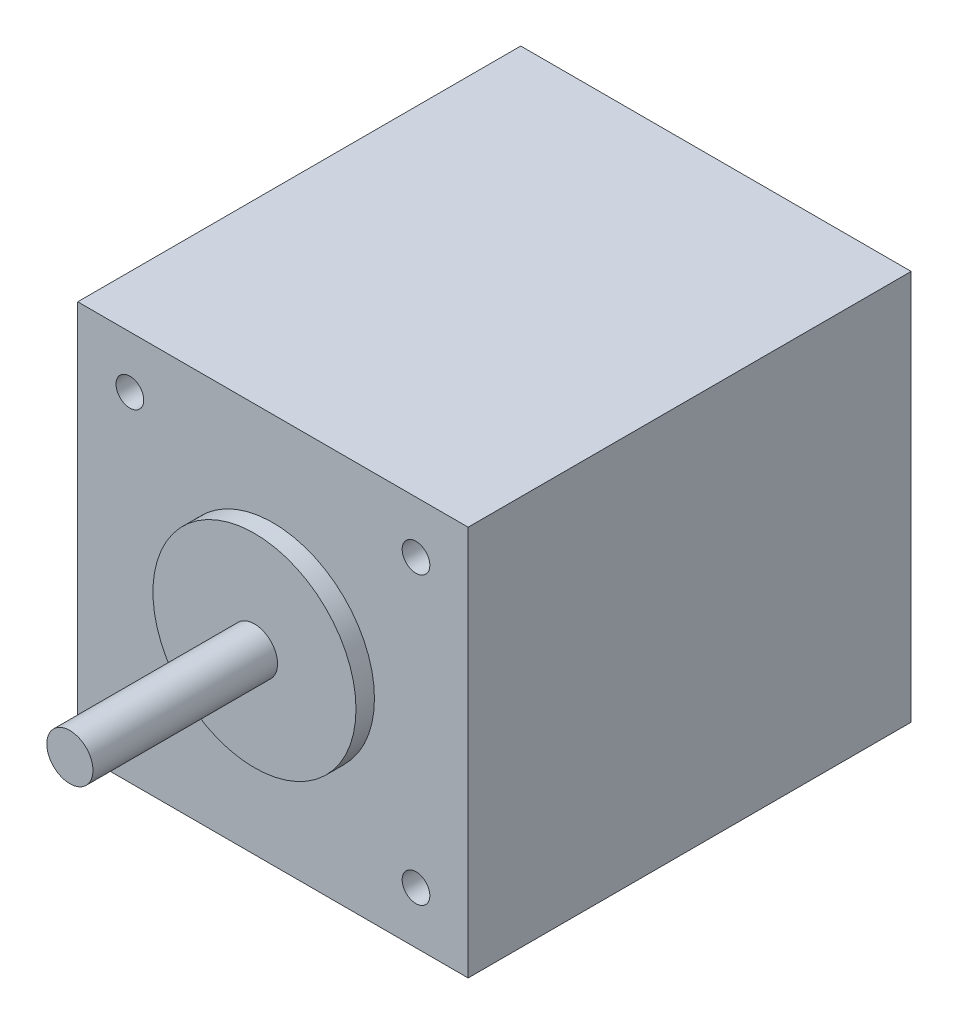
from build123d import *

# Parameters (mm, degrees)
ESQUISSE1_W                       = 48
ESQUISSE1_H                       = 42.3
BOSS_EXTRU_1_DEPTH                = 42.3
DIAM_TRE_DU_PER_AGE_3_0_3_1_D     = 3
DIAM_TRE_DU_PER_AGE_3_0_3_1_DEPTH = 5


with BuildPart() as part:
    # Esquisse1 → Boss.-Extru.1 (new body)
    with BuildSketch(Plane(origin=(21.15, 0, 0), x_dir=(0, 0, -1), z_dir=(1, 0, 0))):
        with Locations((24, 0)):
            Rectangle(ESQUISSE1_W, ESQUISSE1_H)
    extrude(amount=-BOSS_EXTRU_1_DEPTH)

    # Esquisse2 → Révolution1 (revolve)
    with BuildSketch(Plane(origin=(0, 0, 0), x_dir=(1, 0, 0), z_dir=(0, 1, 0))):
        Polygon((11, 0), (0, 0), (0, -22), (2.5, -22), (2.5, -2), (11, -2), align=None)
    revolve(axis=Axis((0, 0, 0), (0, 0, 1)))

    # Diamètre du perçage Ø3.0 (3)1
    with Locations(Plane.XY):
        with Locations((15.5, 15.5), (15.5, -15.5), (-15.5, 15.5), (-15.5, -15.5)):
            Hole(DIAM_TRE_DU_PER_AGE_3_0_3_1_D / 2, depth=DIAM_TRE_DU_PER_AGE_3_0_3_1_DEPTH)


solid = part.part
